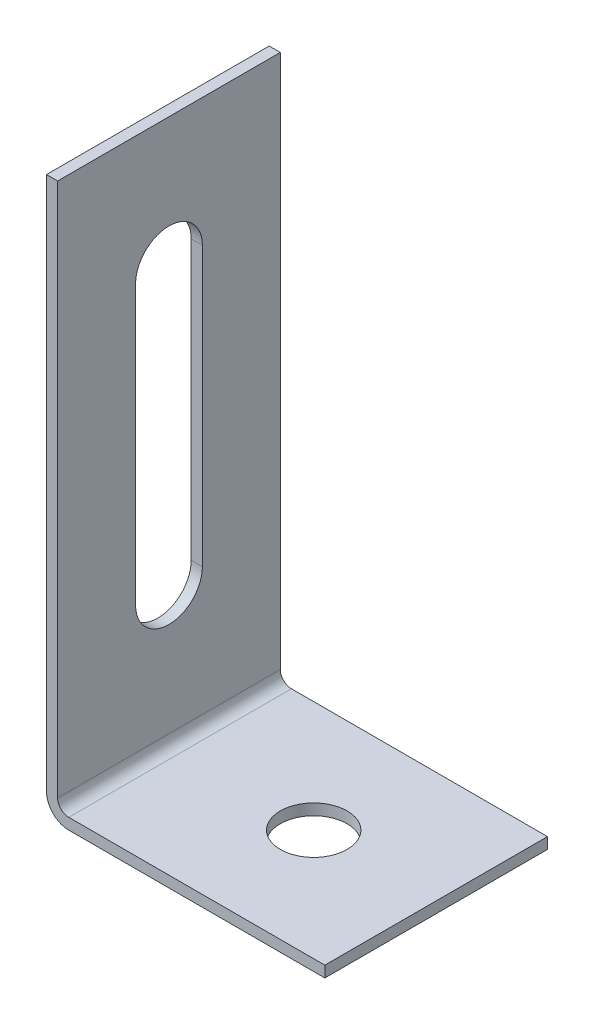
from build123d import *

# Parameters (mm, degrees)
BOSS_EXTRUDE1_DEPTH = 20
CUT_EXTRUDE1_DEPTH  = 10
SKETCH4_R           = 3
CUT_EXTRUDE2_DEPTH  = 10


with BuildPart() as part:
    # Sketch2 → Boss-Extrude1 (new body)
    with BuildSketch(Plane.XY):
        with BuildLine():
            Line((0, 2), (0, 50))
            Line((0, 50), (1, 50))
            Line((1, 50), (1, 2))
            ThreePointArc((1, 2), (1.292893219, 1.292893219), (2, 1))
            Line((2, 1), (25, 1))
            Line((25, 1), (25, 0))
            Line((25, 0), (2, 0))
            ThreePointArc((2, 0), (0.585786438, 0.585786438), (0, 2))
        make_face()
    extrude(amount=BOSS_EXTRUDE1_DEPTH)

    # Sketch3 → Cut-Extrude1 (cut)
    with BuildSketch(Plane(origin=(1, 0, 0), x_dir=(0, 0, -1), z_dir=(1, 0, 0))):
        with BuildLine():
            Line((-13, 13.5), (-13, 38.5))
            ThreePointArc((-13, 38.5), (-10, 41.5), (-7, 38.5))
            Line((-7, 38.5), (-7, 13.5))
            ThreePointArc((-7, 13.5), (-10, 10.5), (-13, 13.5))
        make_face()
    extrude(amount=-CUT_EXTRUDE1_DEPTH, mode=Mode.SUBTRACT)

    # Sketch4 → Cut-Extrude2 (cut)
    with BuildSketch(Plane(origin=(0, 1, 0), x_dir=(1, 0, 0), z_dir=(0, 1, 0))):
        with Locations((14, -10)):
            Circle(SKETCH4_R)
    extrude(amount=-CUT_EXTRUDE2_DEPTH, mode=Mode.SUBTRACT)


solid = part.part
